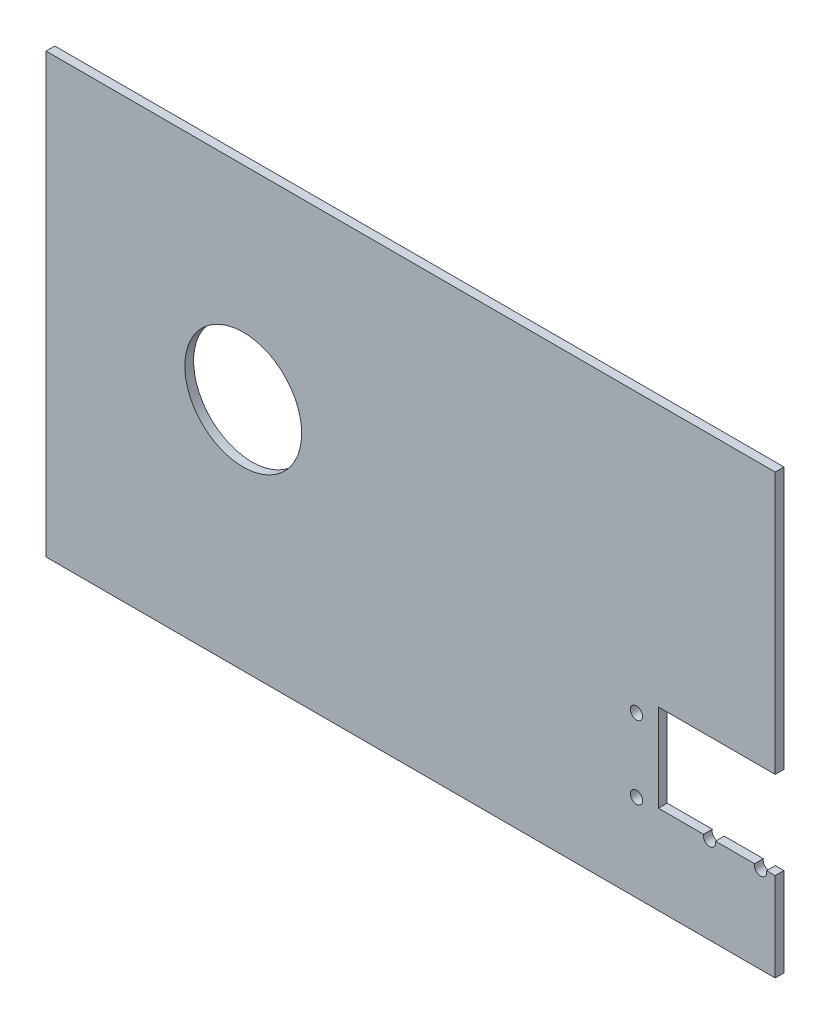
from build123d import *

# Parameters (mm, degrees)
SKETCH1_W           = 249.6
SKETCH1_H           = 150
BOSS_EXTRUDE1_DEPTH = 3
SKETCH2_R           = 20
CUT_EXTRUDE1_DEPTH  = 4
SKETCH3_W           = 40
SKETCH3_H           = 30
CUT_EXTRUDE2_DEPTH  = 5
SKETCH4_R           = 2.1
SKETCH4_R_2         = 4
CUT_EXTRUDE3_DEPTH  = 4


with BuildPart() as part:
    # Sketch1 → Boss-Extrude1 (new body)
    with BuildSketch(Plane.XY):
        with Locations((124.8, -75)):
            Rectangle(SKETCH1_W, SKETCH1_H)
    extrude(amount=BOSS_EXTRUDE1_DEPTH)

    # Sketch2 → Cut-Extrude1 (cut, through all)
    with BuildSketch(Plane.XY.offset(3)):
        with Locations((67.5, -69.58494332)):
            Circle(SKETCH2_R)
    extrude(amount=-CUT_EXTRUDE1_DEPTH, mode=Mode.SUBTRACT)

    # Sketch3 → Cut-Extrude2 (cut)
    with BuildSketch(Plane.XY.offset(3)):
        with Locations((229.6, -104.652337216)):
            Rectangle(SKETCH3_W, SKETCH3_H)
    extrude(amount=-CUT_EXTRUDE2_DEPTH, mode=Mode.SUBTRACT)

    # Sketch4 → Cut-Extrude3 (cut, through all)
    with BuildSketch(Plane.XY.offset(3)):
        with Locations((244.6, -120.152337216)):
            Circle(SKETCH4_R)
        with Locations((227.1, -120.152337216)):
            Circle(SKETCH4_R)
        with Locations((239.6, -107.652337216)):
            Circle(SKETCH4_R_2)
        with Locations((244.6, -95.152337216)):
            Circle(SKETCH4_R)
        with Locations((227.1, -95.152337216)):
            Circle(SKETCH4_R)
        with Locations((202.1, -120.152337216)):
            Circle(SKETCH4_R)
        with Locations((202.1, -95.152337216)):
            Circle(SKETCH4_R)
        with Locations((214.6, -107.652337216)):
            Circle(SKETCH4_R_2)
    extrude(amount=-CUT_EXTRUDE3_DEPTH, mode=Mode.SUBTRACT)


solid = part.part
